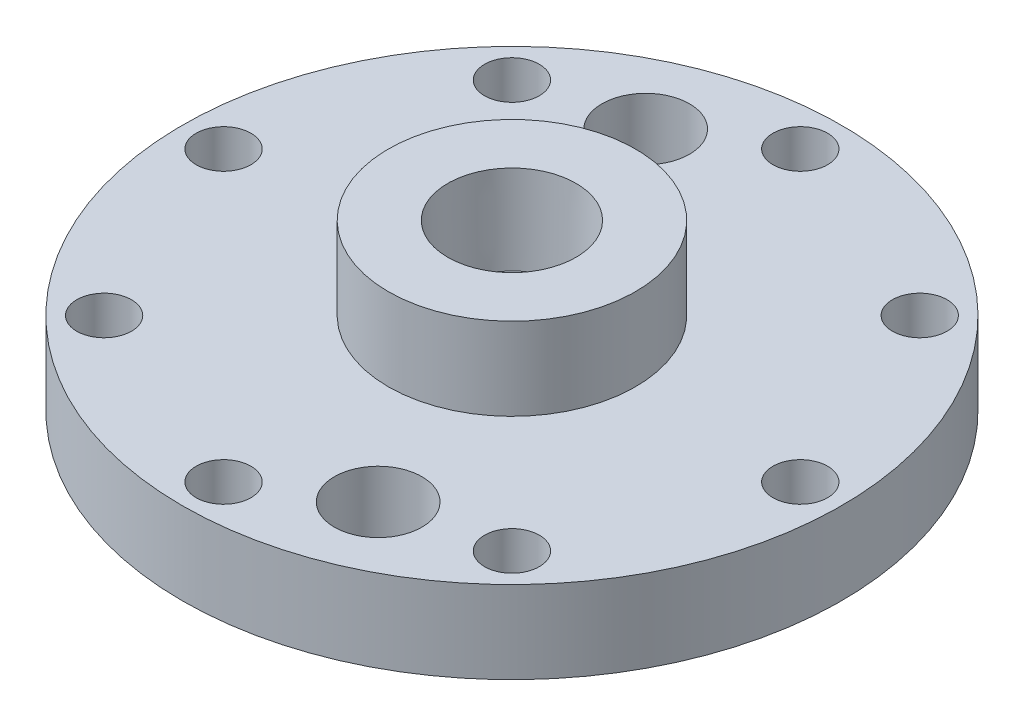
from build123d import *

# Parameters (mm, degrees)
F_5_16_CLEARANCE_HOLE1_D = 8.4328
CIRPATTERN1_COUNT        = 8
F_1_2_CLEARANCE_HOLE1_D  = 13.49248
CIRPATTERN2_COUNT        = 2


with BuildPart() as part:
    # Sketch1 → Revolve1 (revolve)
    with BuildSketch(Plane.XY):
        Polygon((-19.431, 0), (-50.8, 0), (-50.8, 12.7), (-19.05, 12.7), (-19.05, 25.4), (0, 25.4), (0, 0), (-15.875, 0), (-15.875, 2.54), (-19.431, 2.54), align=None)
    revolve(axis=Axis((0, 25.4, 0), (0, -1, 0)))

    # Sketch4 → 1/2 NPT Tapped Hole1 (revolve, cut)
    with BuildSketch(Plane(origin=(0, 25.4, 0), x_dir=(0, 0, 1), z_dir=(1, 0, 0))):
        Polygon((0, 0), (0, 25.4), (8.9281, 25.4), (8.9281, 13.462), (9.479726792, 13.462), (9.8827971, 0), align=None)
    revolve(axis=Axis((0, 31.75, 0), (0, -1, 0)), mode=Mode.SUBTRACT)

    # 5/16 Clearance Hole1 (through all)
    with Locations(Plane(origin=(0, 12.7, 0), x_dir=(1, 0, 0), z_dir=(0, 1, 0))):
        with Locations((44.45, 0)):
            f_5_16_clearance_hole1 = Hole(F_5_16_CLEARANCE_HOLE1_D / 2)

    # CirPattern1: 5/16 Clearance Hole1 ×8 about axis
    cirpattern1_axis = Axis((0, 0, 0), (0, 1, 0))
    for i in range(1, CIRPATTERN1_COUNT):
        add(f_5_16_clearance_hole1.rotate(cirpattern1_axis, i * 360 / CIRPATTERN1_COUNT), mode=Mode.SUBTRACT)

    # 1/2 Clearance Hole1 (through all)
    with Locations(Plane(origin=(0, 12.7, 0), x_dir=(1, 0, 0), z_dir=(0, 1, 0))):
        with Locations((-14.580238773, 35.199810189)):
            f_1_2_clearance_hole1 = Hole(F_1_2_CLEARANCE_HOLE1_D / 2)

    # CirPattern2: 1/2 Clearance Hole1 ×2 about axis
    cirpattern2_axis = Axis((0, 0, 0), (0, 1, 0))
    for i in range(1, CIRPATTERN2_COUNT):
        add(f_1_2_clearance_hole1.rotate(cirpattern2_axis, i * 360 / CIRPATTERN2_COUNT), mode=Mode.SUBTRACT)


solid = part.part
